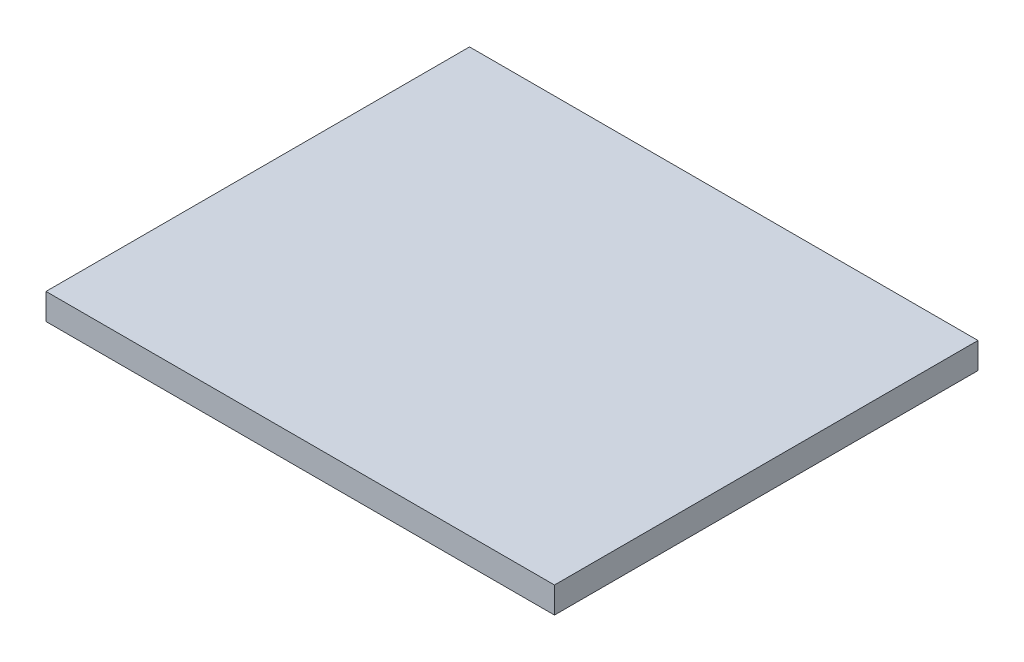
from build123d import *

# Parameters (mm, degrees)
BOSS_EXTRUDE1_DEPTH = 0.01
BOSS_EXTRUDE2_DEPTH = 0.43


with BuildPart() as part:
    # Sketch1 → Boss-Extrude1 (new body)
    with BuildSketch(Plane(origin=(0, 0, 0), x_dir=(1, 0, 0), z_dir=(0, 1, 0))):
        Polygon((2.625, 3.425), (2.625, 0.425), (4.125, 0.425), (4.125, -3.425), (-0.425, -3.425), (-0.425, 3.425), align=None)
    extrude(amount=BOSS_EXTRUDE1_DEPTH)

    # Sketch2 → Boss-Extrude2 (add)
    with BuildSketch(Plane(origin=(0, 0.01, 0), x_dir=(1, 0, 0), z_dir=(0, 1, 0))):
        Polygon((4.19, 3.49), (0, 3.49), (-4.19, 3.49), (-4.19, -3.49), (0, -3.49), (4.19, -3.49), align=None)
    extrude(amount=BOSS_EXTRUDE2_DEPTH)


solid = part.part
